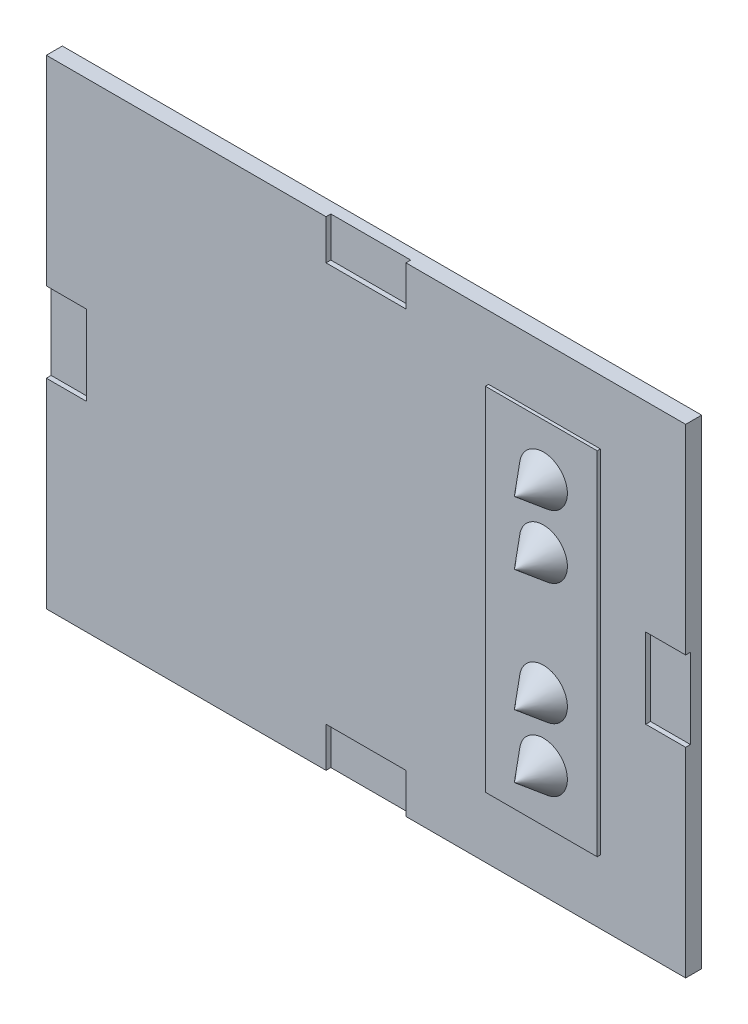
from build123d import *

# Parameters (mm, degrees)
SKETCH1_W           = 40
SKETCH1_H           = 30
BOSS_EXTRUDE1_DEPTH = 1
SKETCH1_4_W         = 7
SKETCH1_4_H         = 22
BOSS_EXTRUDE2_DEPTH = 1.2
SKETCH2_W           = 5
SKETCH2_H           = 2.5
SKETCH2_W_2         = 2.5
SKETCH2_H_2         = 5
CUT_EXTRUDE15_DEPTH = 0.3
SKETCH3_R           = 1.5
BOSS_EXTRUDE3_DEPTH = 1.8
BOSS_EXTRUDE3_TAPER = 39.5


with BuildPart() as part:
    # Sketch1 → Boss-Extrude1 (new body)
    with BuildSketch(Plane.XY):
        Rectangle(SKETCH1_W, SKETCH1_H)
    extrude(amount=BOSS_EXTRUDE1_DEPTH)

    # Sketch1_4 → Boss-Extrude2 (add)
    with BuildSketch(Plane.XY):
        with Locations((11.166666667, 0)):
            Rectangle(SKETCH1_4_W, SKETCH1_4_H)
    extrude(amount=BOSS_EXTRUDE2_DEPTH)

    # Sketch2 → Cut-Extrude15 (cut)
    with BuildSketch(Plane.XY.offset(1)):
        with Locations((0, -13.75)):
            Rectangle(SKETCH2_W, SKETCH2_H)
        with Locations((-18.75, 0)):
            Rectangle(SKETCH2_W_2, SKETCH2_H_2)
        with Locations((18.75, 0)):
            Rectangle(SKETCH2_W_2, SKETCH2_H_2)
        with Locations((0, 13.75)):
            Rectangle(SKETCH2_W, SKETCH2_H)
    extrude(amount=-CUT_EXTRUDE15_DEPTH, mode=Mode.SUBTRACT)

    # Sketch3 → Boss-Extrude3 (add)
    with BuildSketch(Plane.XY.offset(1.2)):
        with Locations((11.3, -7.75)):
            Circle(SKETCH3_R)
        with Locations((11.3, -3.8)):
            Circle(SKETCH3_R)
        with Locations((11.3, 3.8)):
            Circle(SKETCH3_R)
        with Locations((11.3, 7.75)):
            Circle(SKETCH3_R)
    extrude(amount=BOSS_EXTRUDE3_DEPTH, taper=BOSS_EXTRUDE3_TAPER)


solid = part.part
